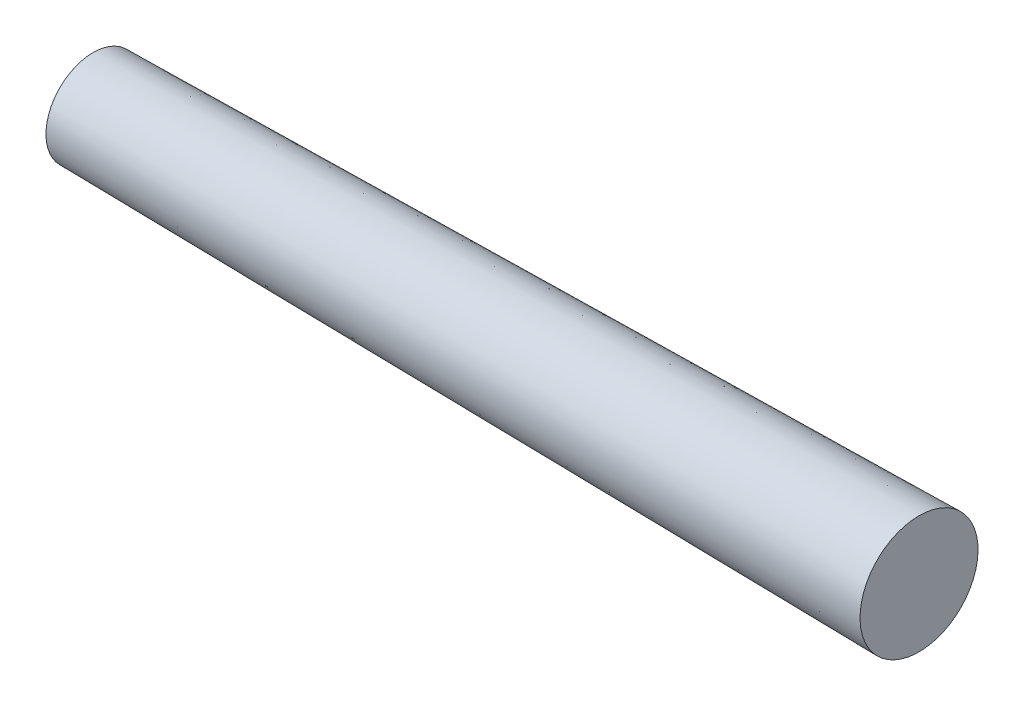
from build123d import *


with BuildPart() as part:
    # Sketch1 → Revolve1 (revolve)
    with BuildSketch(Plane.XY):
        Polygon((0, 0), (0, 2), (35, 2.5), (35, 0), align=None)
    revolve(axis=Axis((35, 0, 0), (-1, 0, 0)))


solid = part.part
